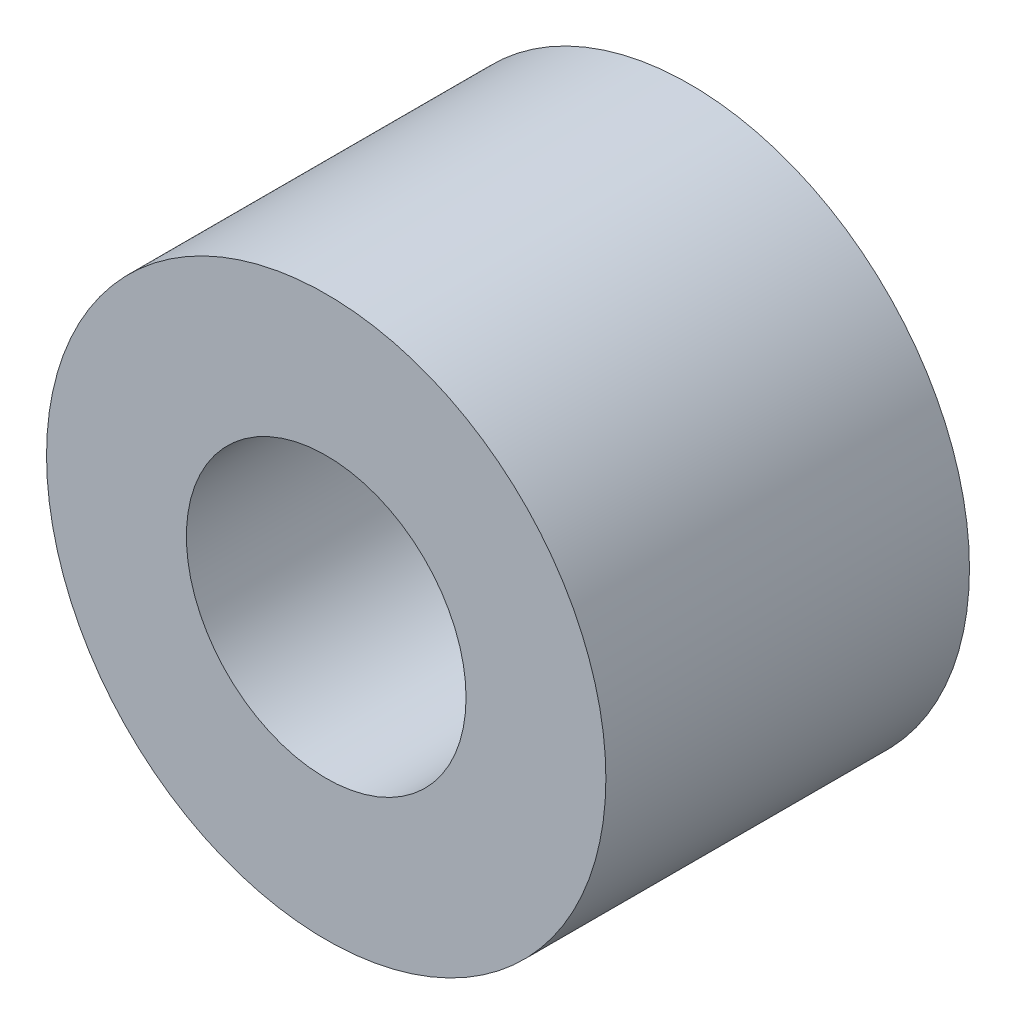
from build123d import *

# Parameters (mm, degrees)
SKETCH1_R           = 5
SKETCH1_R_2         = 2.5
BOSS_EXTRUDE1_DEPTH = 6.5


with BuildPart() as part:
    # Sketch1 → Boss-Extrude1 (new body)
    with BuildSketch(Plane.XY):
        Circle(SKETCH1_R)
        Circle(SKETCH1_R_2, mode=Mode.SUBTRACT)
    extrude(amount=BOSS_EXTRUDE1_DEPTH)


solid = part.part
